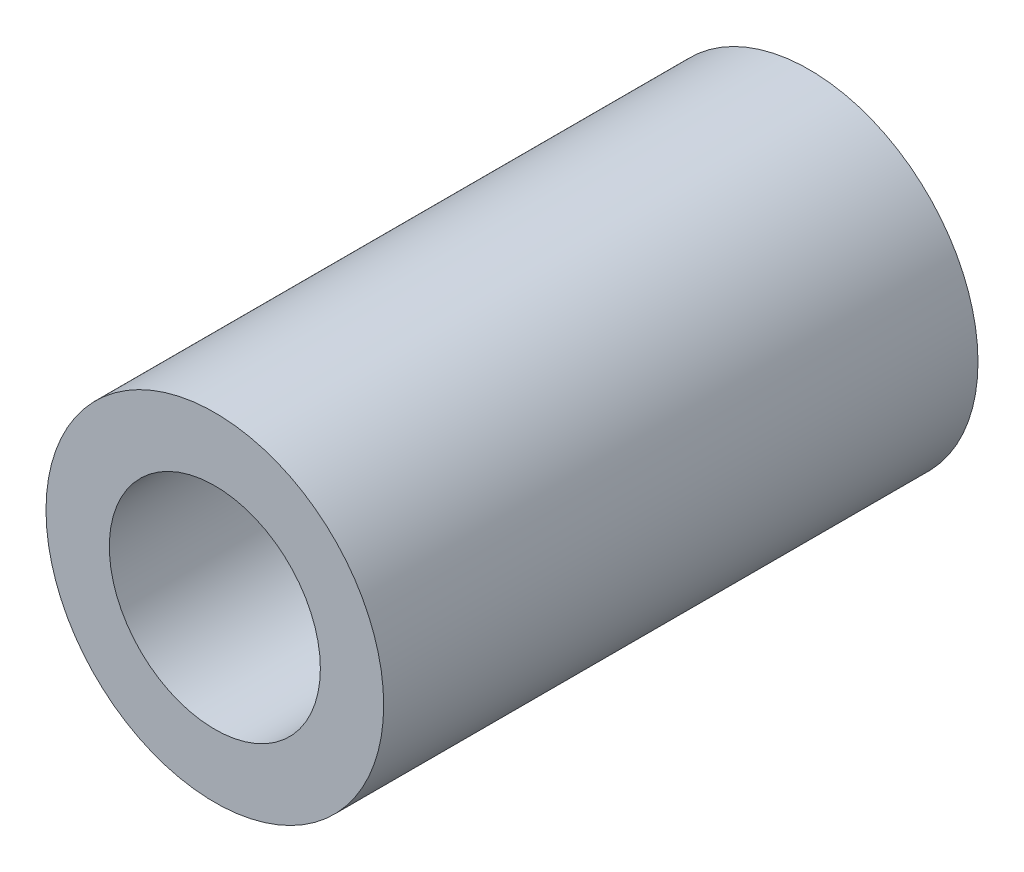
from build123d import *

# Parameters (mm, degrees)
SKETCH1_R           = 1.5875
BOSS_EXTRUDE1_DEPTH = 5.588
CUT_EXTRUDE1_REACH  = 7.588
SKETCH3_R           = 0.9921875


with BuildPart() as part:
    # Sketch1 → Boss-Extrude1 (new body)
    with BuildSketch(Plane.XY):
        Circle(SKETCH1_R)
    extrude(amount=BOSS_EXTRUDE1_DEPTH)

    # Sketch3 → Cut-Extrude1 (cut, up to next)
    with BuildSketch(Plane.XY.offset(5.588), mode=Mode.PRIVATE) as cut_extrude1_sk1:
        Circle(SKETCH3_R)
    cut_extrude1_tool1 = extrude(cut_extrude1_sk1.sketch, amount=-CUT_EXTRUDE1_REACH, mode=Mode.PRIVATE) & part.part
    add(cut_extrude1_tool1.solids().sort_by_distance((0, 0, 5.588))[0], mode=Mode.SUBTRACT)


solid = part.part
